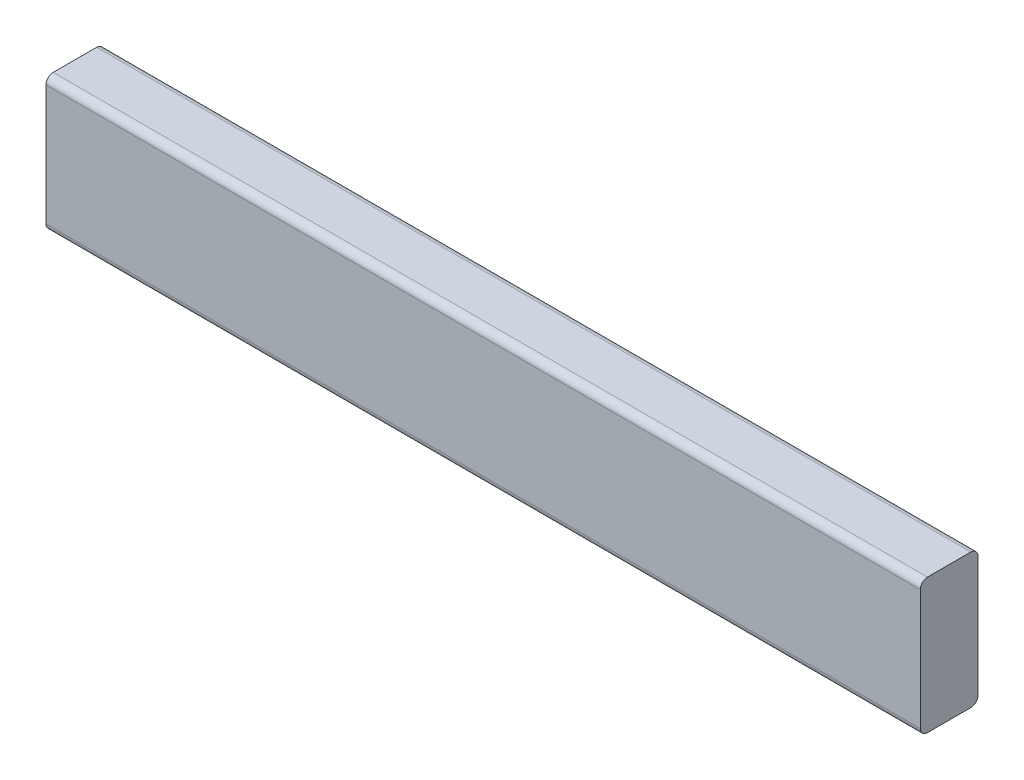
from build123d import *

# Parameters (mm, degrees)
SKETCH1_W           = 576.798406726
SKETCH1_H           = 88.9
BOSS_EXTRUDE1_DEPTH = 38.1
FILLET1_R           = 4.7625


with BuildPart() as part:
    # Sketch1 → Boss-Extrude1 (new body)
    with BuildSketch(Plane.XY):
        with Locations((-493.331391288, 44.45)):
            Rectangle(SKETCH1_W, SKETCH1_H)
    extrude(amount=-BOSS_EXTRUDE1_DEPTH)

    # Fillet1
    fillet1_edges = [part.edges().sort_by_distance(p)[0] for p in [
        (-493.331391288, 88.9, -38.1),
        (-493.331391288, 0, -38.1),
        (-493.331391288, 88.9, 0),
        (-493.331391288, 0, 0),
    ]]
    fillet(fillet1_edges, radius=FILLET1_R)


solid = part.part
